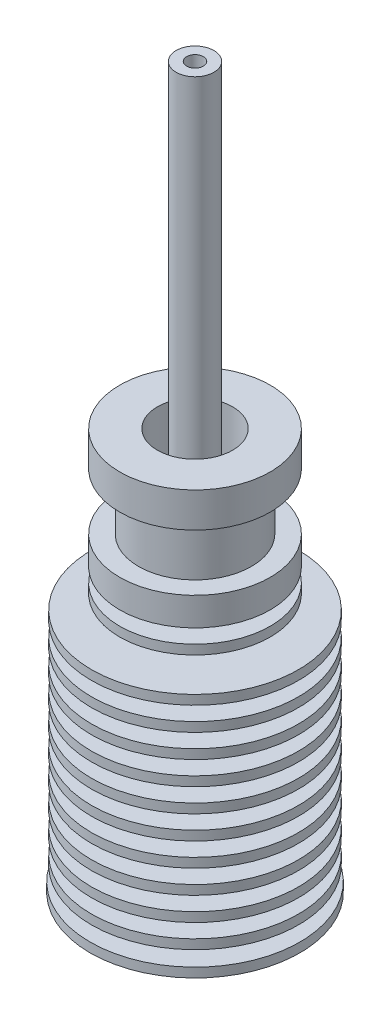
from build123d import *

# Parameters (mm, degrees)
SKETCH2_W                 = 5
SKETCH2_H                 = 1.5
LPATTERN1_COUNT           = 10
LPATTERN1_PITCH           = 2.5
M7X1_0_TAPPED_HOLE1_D     = 6
M7X1_0_TAPPED_HOLE1_DEPTH = 15.1
M7X1_0_TAPPED_HOLE1_TIP   = 1.802581857
SKETCH6_W                 = 1.12
SKETCH6_H                 = 40.496575644


with BuildPart() as part:
    # Sketch1 → Revolve1 (revolve)
    with BuildSketch(Plane.XY):
        Polygon((0, 42.7), (0, 0), (11.15, 0), (11.15, 1), (11, 1), (11, 26), (3.5, 26), (3.5, 27.5), (8, 27.5), (8, 28.5), (3.5, 28.5), (3.5, 30), (8, 30), (8, 33), (6, 33), (6, 39), (8, 39), (8, 42.7), align=None)
    revolve(axis=Axis((0, 0, 0), (0, -1, 0)))

    # Sketch2 → Cut-Revolve1 (revolve, cut)
    with BuildSketch(Plane.XY):
        with Locations((8.5, 1.75)):
            Rectangle(SKETCH2_W, SKETCH2_H)
    cut_revolve1 = revolve(axis=Axis((0, 0, 0), (0, 1, 0)), mode=Mode.SUBTRACT)

    # LPattern1: Cut-Revolve1 ×10
    with Locations(*[(0, i * LPATTERN1_PITCH, 0) for i in range(1, LPATTERN1_COUNT)]):
        add(cut_revolve1, mode=Mode.SUBTRACT)

    # Sketch3 → Cut-Revolve2 (revolve, cut)
    with BuildSketch(Plane.XY):
        Polygon((0, 42.7), (0, 0), (2.1, 0), (2.1, 34.3), (4, 36.2), (4, 42.7), align=None)
    revolve(axis=Axis((0, 42.7, 0), (0, -1, 0)), mode=Mode.SUBTRACT)

    # M7x1.0 Tapped Hole1
    with Locations(Plane(origin=(0, 0, 0), x_dir=(-1, 0, 0), z_dir=(0, -1, 0))):
        with Locations((0, 0)):
            Hole(M7X1_0_TAPPED_HOLE1_D / 2, depth=M7X1_0_TAPPED_HOLE1_DEPTH)
            with Locations((0, 0, -(M7X1_0_TAPPED_HOLE1_DEPTH + M7X1_0_TAPPED_HOLE1_TIP / 2))):  # 118° drill point
                Cone(0, M7X1_0_TAPPED_HOLE1_D / 2, M7X1_0_TAPPED_HOLE1_TIP, mode=Mode.SUBTRACT)


with BuildPart() as body_2:
    # Sketch6 → Revolve2 (revolve)
    with BuildSketch(Plane.XY):
        with Locations((1.445, 56.248287822)):
            Rectangle(SKETCH6_W, SKETCH6_H)
    revolve(axis=Axis((0, 0, 0), (0, 1, 0)))


solid = Compound([part.part, body_2.part])
